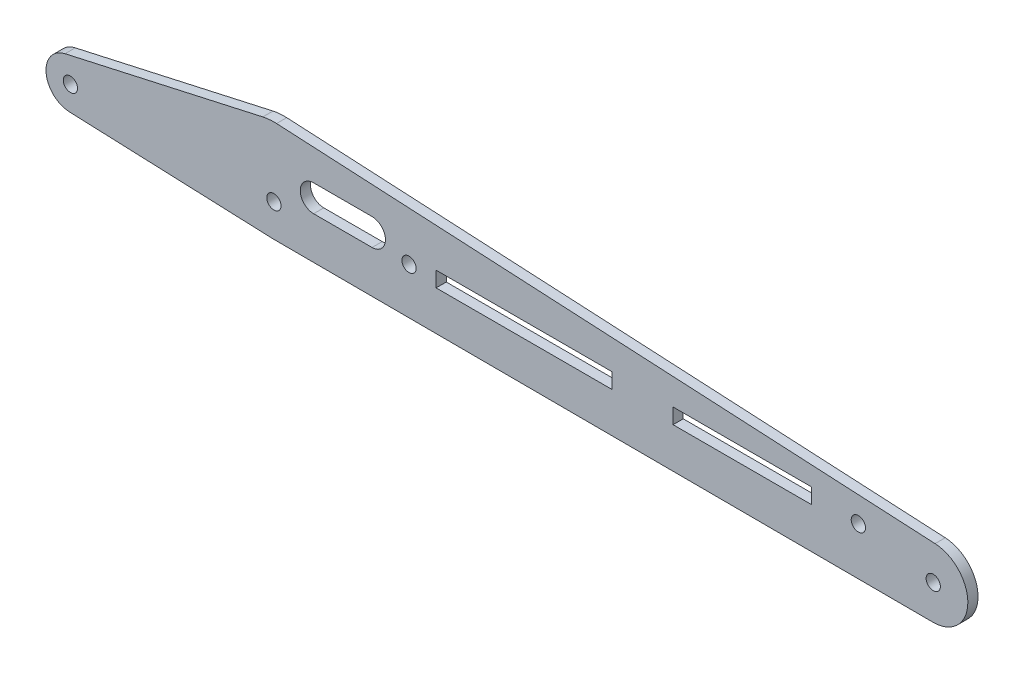
from build123d import *

# Parameters (mm, degrees)
SKETCH_1_R          = 1.75
EXTRUDE_2_DEPTH     = 2.5
SKETCH_2_W          = 43.174936718
SKETCH_2_H          = 3.770638763
SKETCH_2_W_2        = 34.014564127
CUT_EXTRUDE_1_DEPTH = 3.5
SKETCH_3_R          = 1.75
CUT_EXTRUDE_2_DEPTH = 3.5


with BuildPart() as part:
    # 草图1 → 凸台-拉伸2 (new body)
    with BuildSketch(Plane.XY):
        with BuildLine():
            ThreePointArc((-1.307031792, 5.855908802), (-5.975846633, -0.537826197), (-0.240433737, -5.995180699))
            Line((-0.240433737, -5.995180699), (49.499096381, -7.98995979))
            ThreePointArc((49.499096381, -7.98995979), (49.730212736, -7.997088254), (49.961421407, -7.999940468))
            Line((49.961421407, -7.999940468), (49.999999816, -8.000059532))
            Line((49.999999816, -8.000059532), (211.973766557, -8.499959518))
            ThreePointArc((211.973766557, -8.499959518), (220.496722576, -0.236020072), (212.445662896, 8.4883087))
            Line((212.445662896, 8.4883087), (50.655386612, 16.982806911))
            ThreePointArc((50.655386612, 16.982806911), (50.327806045, 16.995700989), (50, 17))
            ThreePointArc((50, 17), (48.630260069, 16.924725853), (47.2770171, 16.699810004))
            Line((47.2770171, 16.699810004), (-1.307031792, 5.855908802))
        make_face()
        Circle(SKETCH_1_R, mode=Mode.SUBTRACT)
        with Locations((50, 0)):
            Circle(SKETCH_1_R, mode=Mode.SUBTRACT)
        with Locations((212, 0)):
            Circle(SKETCH_1_R, mode=Mode.SUBTRACT)
    extrude(amount=EXTRUDE_2_DEPTH)

    # 草图2 → 切除-拉伸1 (cut, through all)
    with BuildSketch(Plane.XY.offset(2.5)):
        with BuildLine():
            Line((59.758236221, 8.91451918), (74.115618559, 8.91451918))
            ThreePointArc((74.115618559, 8.91451918), (77.403568713, 5.626569026), (74.115618559, 2.338618872))
            Line((74.115618559, 2.338618872), (59.758236221, 2.338618872))
            ThreePointArc((59.758236221, 2.338618872), (56.470286067, 5.626569026), (59.758236221, 8.91451918))
        make_face()
        with Locations((111.440293999, 3.490211277)):
            Rectangle(SKETCH_2_W, SKETCH_2_H)
        with Locations((165.07921871, 3.490211277)):
            Rectangle(SKETCH_2_W_2, SKETCH_2_H)
    extrude(amount=-CUT_EXTRUDE_1_DEPTH, mode=Mode.SUBTRACT)

    # 草图3 → 切除-拉伸2 (cut, through all)
    with BuildSketch(Plane.XY.offset(2.5)):
        with BuildLine():
            ThreePointArc((84.93827664, 3.287023225), (83.18827664, 5.037023225), (81.43827664, 3.287023225))
            Line((81.43827664, 3.287023225), (84.93827664, 3.287023225))
        make_face()
        with BuildLine():
            Line((84.93827664, 3.287023225), (81.43827664, 3.287023225))
            ThreePointArc((81.43827664, 3.287023225), (83.18827664, 1.537023225), (84.93827664, 3.287023225))
        make_face()
        with Locations((193.595777353, 3.287023225)):
            Circle(SKETCH_3_R)
    extrude(amount=-CUT_EXTRUDE_2_DEPTH, mode=Mode.SUBTRACT)


solid = part.part
